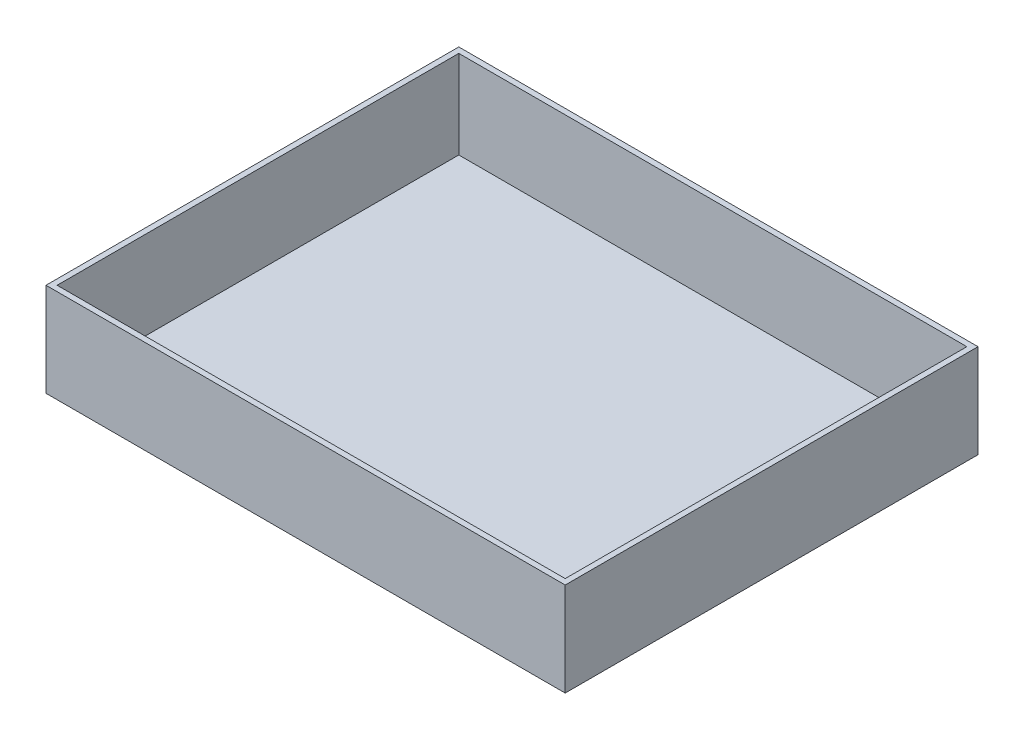
from build123d import *

# Parameters (mm, degrees)
SKETCH1_W           = 466
SKETCH1_H           = 370.5
BOSS_EXTRUDE1_DEPTH = 84
SKETCH2_W           = 456
SKETCH2_H           = 360.5
CUT_EXTRUDE1_DEPTH  = 79


with BuildPart() as part:
    # Sketch1 → Boss-Extrude1 (new body)
    with BuildSketch(Plane(origin=(0, 0, 0), x_dir=(1, 0, 0), z_dir=(0, 1, 0))):
        with Locations((233, 185.25)):
            Rectangle(SKETCH1_W, SKETCH1_H)
    extrude(amount=BOSS_EXTRUDE1_DEPTH)

    # Sketch2 → Cut-Extrude1 (cut)
    with BuildSketch(Plane(origin=(0, 84, 0), x_dir=(1, 0, 0), z_dir=(0, 1, 0))):
        with Locations((233, 185.25)):
            Rectangle(SKETCH2_W, SKETCH2_H)
    extrude(amount=-CUT_EXTRUDE1_DEPTH, mode=Mode.SUBTRACT)


solid = part.part
